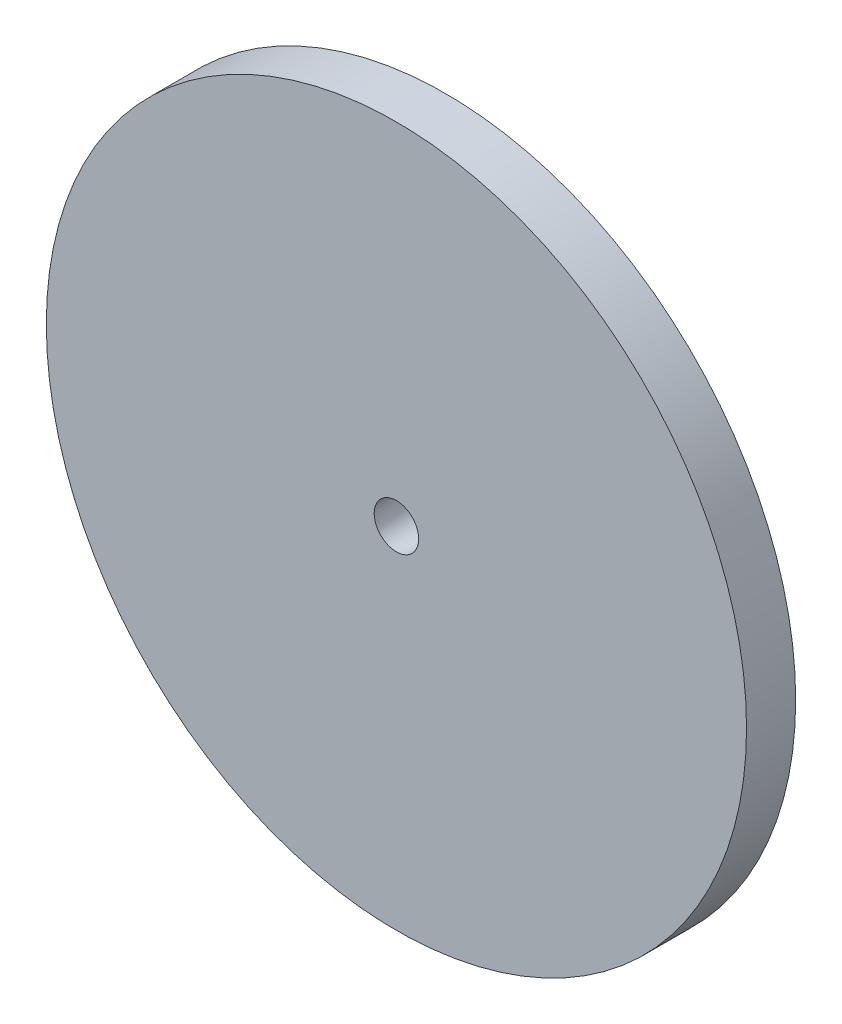
from build123d import *

# Parameters (mm, degrees)
SKETCH1_R           = 38.000051
BOSS_EXTRUDE1_DEPTH = 5.334
SKETCH2_R           = 2.413
CUT_EXTRUDE1_DEPTH  = 6.334


with BuildPart() as part:
    # Sketch1 → Boss-Extrude1 (new body)
    with BuildSketch(Plane.XY):
        Circle(SKETCH1_R)
    extrude(amount=BOSS_EXTRUDE1_DEPTH)

    # Sketch2 → Cut-Extrude1 (cut, through all)
    with BuildSketch(Plane.XY.offset(5.334)):
        Circle(SKETCH2_R)
    extrude(amount=-CUT_EXTRUDE1_DEPTH, mode=Mode.SUBTRACT)


solid = part.part
